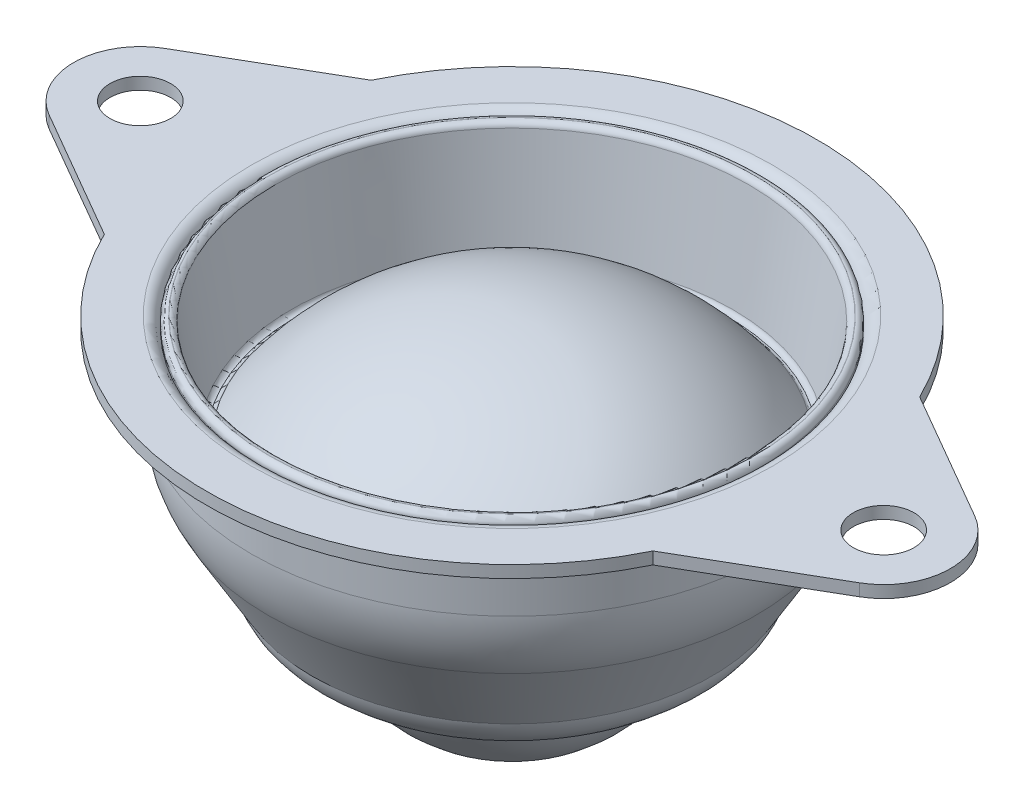
from build123d import *

# Parameters (mm, degrees)
CROQUIS2_R              = 2.5
SALIENTE_EXTRUIR1_DEPTH = 1


with BuildPart() as part:
    # Croquis1 → Revolución1 (revolve)
    with BuildSketch(Plane(origin=(0, 0, 0), x_dir=(0, 0, -1), z_dir=(1, 0, 0))):
        with BuildLine():
            Line((-25.15, -1), (-22.5, -1))
            ThreePointArc((-22.5, -1), (-21.792893219, -1.292893219), (-21.5, -2))
            Line((-21.5, -2), (-21.5, -6.276917077))
            ThreePointArc((-21.5, -6.276917077), (-21.148663677, -8.904328206), (-20.119342152, -11.347118342))
            Line((-20.119342152, -11.347118342), (-16.5, -17.5))
            ThreePointArc((-16.5, -17.5), (-14.833846069, -19.875769103), (-12, -20.5))
            Line((-12, -20.5), (-12, -19.5))
            ThreePointArc((-12, -19.5), (-14.013899124, -18.562745942), (-15.5, -16.911764706))
            Line((-15.5, -16.911764706), (-19.119342152, -10.758883048))
            ThreePointArc((-19.119342152, -10.758883048), (-20.148663677, -8.316092912), (-20.5, -5.688681783))
            Line((-20.5, -5.688681783), (-20.5, -1))
            ThreePointArc((-20.5, -1), (-20.792893219, -0.292893219), (-21.5, 0))
            Line((-21.5, 0), (-25.15, 0))
            Line((-25.15, 0), (-25.15, -1))
        make_face()
    revolve(axis=Axis((0, 0, 0), (0, -1, 0)))

    # Croquis2 → Saliente-Extruir1 (add)
    with BuildSketch(Plane(origin=(0, 0, 0), x_dir=(1, 0, 0), z_dir=(0, 1, 0))):
        with BuildLine():
            Line((33.403711727, 4.760994825), (22.616863178, 11))
            ThreePointArc((22.616863178, 11), (25.15, 0), (22.616863178, -11))
            Line((22.616863178, -11), (33.403711727, -4.760994825))
            ThreePointArc((33.403711727, -4.760994825), (36.15, 0), (33.403711727, 4.760994825))
        make_face()
        with Locations((30.65, 0)):
            Circle(CROQUIS2_R, mode=Mode.SUBTRACT)
        with BuildLine():
            Line((-22.616863178, -11), (-33.403711727, -4.760994825))
            ThreePointArc((-33.403711727, -4.760994825), (-36.15, 0), (-33.403711727, 4.760994825))
            Line((-33.403711727, 4.760994825), (-22.616863178, 11))
            ThreePointArc((-22.616863178, 11), (-25.15, 0), (-22.616863178, -11))
        make_face()
        with Locations((-30.65, 0)):
            Circle(CROQUIS2_R, mode=Mode.SUBTRACT)
    extrude(amount=-SALIENTE_EXTRUIR1_DEPTH)


with BuildPart() as body_2:
    # Croquis3 → Revolución2 (revolve)
    with BuildSketch(Plane(origin=(0, 0, 0), x_dir=(0, 0, -1), z_dir=(1, 0, 0))):
        with BuildLine():
            Line((-20.509213545, -0.567415346), (-19, -10))
            Line((-19, -10), (-17.6, -10))
            ThreePointArc((-17.6, -10), (-9.88382517, -3.380519667), (0, -1))
            Line((0, -1), (0, 0))
            ThreePointArc((0, 0), (-9.794006641, -2.334852379), (-17.481267072, -8.837169565))
            ThreePointArc((-17.481267072, -8.837169565), (-17.622909704, -8.956978869), (-17.803370467, -9))
            Line((-17.803370467, -9), (-17.806193243, -9))
            ThreePointArc((-17.806193243, -9), (-18.065732758, -8.90436695), (-18.201169496, -8.6631962))
            Line((-18.201169496, -8.6631962), (-19.521267343, -0.412584654))
            ThreePointArc((-19.521267343, -0.412584654), (-19.687177347, -0.117150487), (-20.005113253, 0))
            Line((-20.005113253, 0), (-20.025367635, 0))
            ThreePointArc((-20.025367635, 0), (-20.398217148, -0.172064094), (-20.509213545, -0.567415346))
        make_face()
    revolve(axis=Axis((0, 0, 0), (0, -1, 0)))


with BuildPart() as body_3:
    # Croquis4 → Revolución3 (revolve)
    with BuildSketch(Plane(origin=(0, 0, 0), x_dir=(0, 0, -1), z_dir=(1, 0, 0))):
        with BuildLine():
            Line((0, -4.6), (0, -29.1))
            ThreePointArc((0, -29.1), (12.25, -16.85), (0, -4.6))
        make_face()
    revolve(axis=Axis((0, -4.6, 0), (0, -1, 0)))


solid = Compound([part.part, body_2.part, body_3.part])
